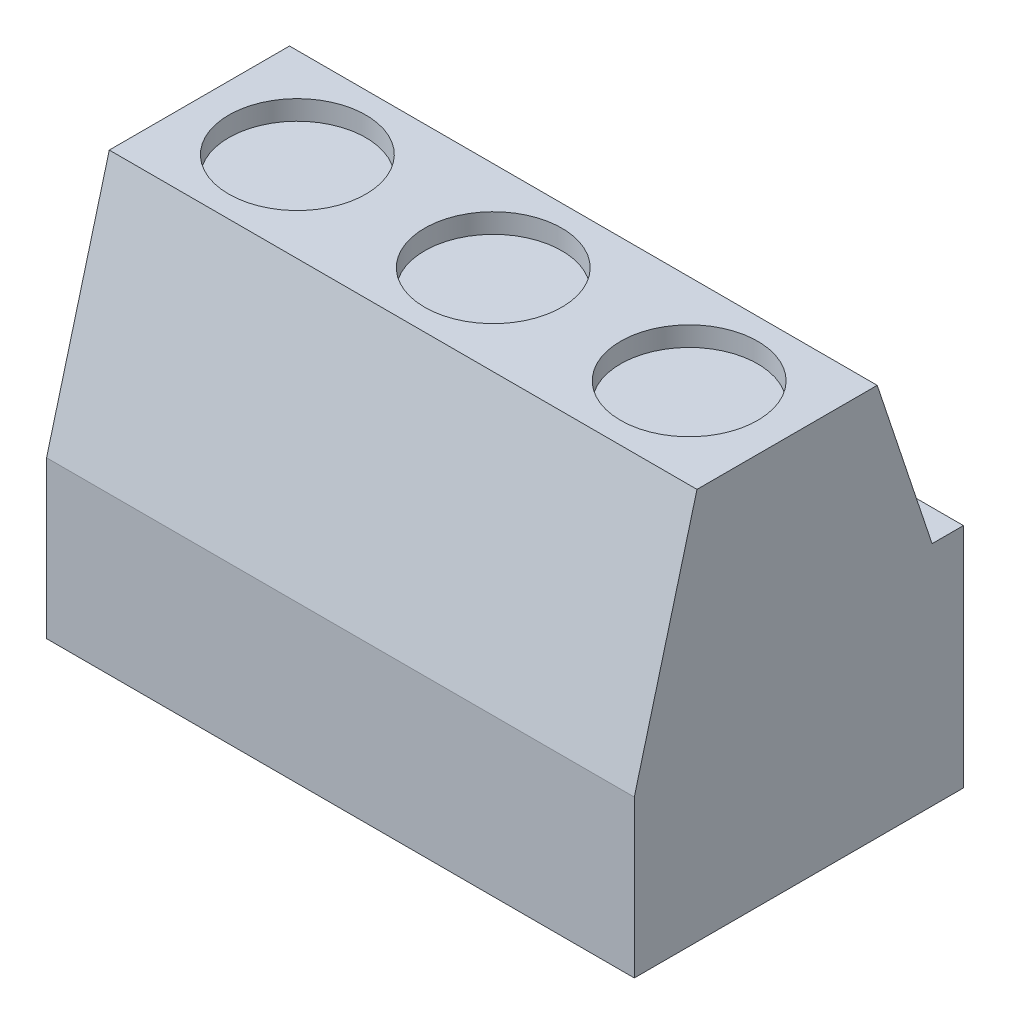
from build123d import *

# Parameters (mm, degrees)
SKETCH3_W           = 15
SKETCH3_H           = 8.4
BOSS_EXTRUDE3_DEPTH = 10
CUT_EXTRUDE1_DEPTH  = 16
SKETCH5_R           = 1.75
CUT_EXTRUDE2_DEPTH  = 0.5
SKETCH6_W           = 3
SKETCH6_H           = 2
CUT_EXTRUDE4_DEPTH  = 0.5
LPATTERN2_COUNT     = 3
LPATTERN2_PITCH     = 5


with BuildPart() as part:
    # Sketch3 → Boss-Extrude3 (new body)
    with BuildSketch(Plane(origin=(0, 0, 0), x_dir=(1, 0, 0), z_dir=(0, 1, 0))):
        Rectangle(SKETCH3_W, SKETCH3_H)
    extrude(amount=BOSS_EXTRUDE3_DEPTH)

    # Sketch4 → Cut-Extrude1 (cut, through all)
    with BuildSketch(Plane.ZY.offset(7.5)):
        Polygon((-3.4, 5.8), (-2, 10), (-3.4, 10), (-4.2, 10), (-4.2, 5.8), align=None)
        Polygon((4.2, 10), (2.6, 10), (4.2, 4), align=None)
    extrude(amount=-CUT_EXTRUDE1_DEPTH, mode=Mode.SUBTRACT)

    # Sketch5 → Cut-Extrude2 (cut)
    with BuildSketch(Plane(origin=(0, 10, 0), x_dir=(1, 0, 0), z_dir=(0, 1, 0))):
        with Locations((-5, -0.3)):
            Circle(SKETCH5_R)
    cut_extrude2 = extrude(amount=-CUT_EXTRUDE2_DEPTH, mode=Mode.SUBTRACT)

    # Sketch6 → Cut-Extrude4 (cut)
    with BuildSketch(Plane(origin=(0, 0, -4.2), x_dir=(-1, 0, 0), z_dir=(0, 0, -1))):
        with Locations((5, 2.4)):
            Rectangle(SKETCH6_W, SKETCH6_H)
    cut_extrude4 = extrude(amount=-CUT_EXTRUDE4_DEPTH, mode=Mode.SUBTRACT)

    # LPattern2: Cut-Extrude2, Cut-Extrude4 ×3
    with Locations(*[(i * LPATTERN2_PITCH, 0, 0) for i in range(1, LPATTERN2_COUNT)]):
        add(cut_extrude2, mode=Mode.SUBTRACT)
        add(cut_extrude4, mode=Mode.SUBTRACT)


solid = part.part
